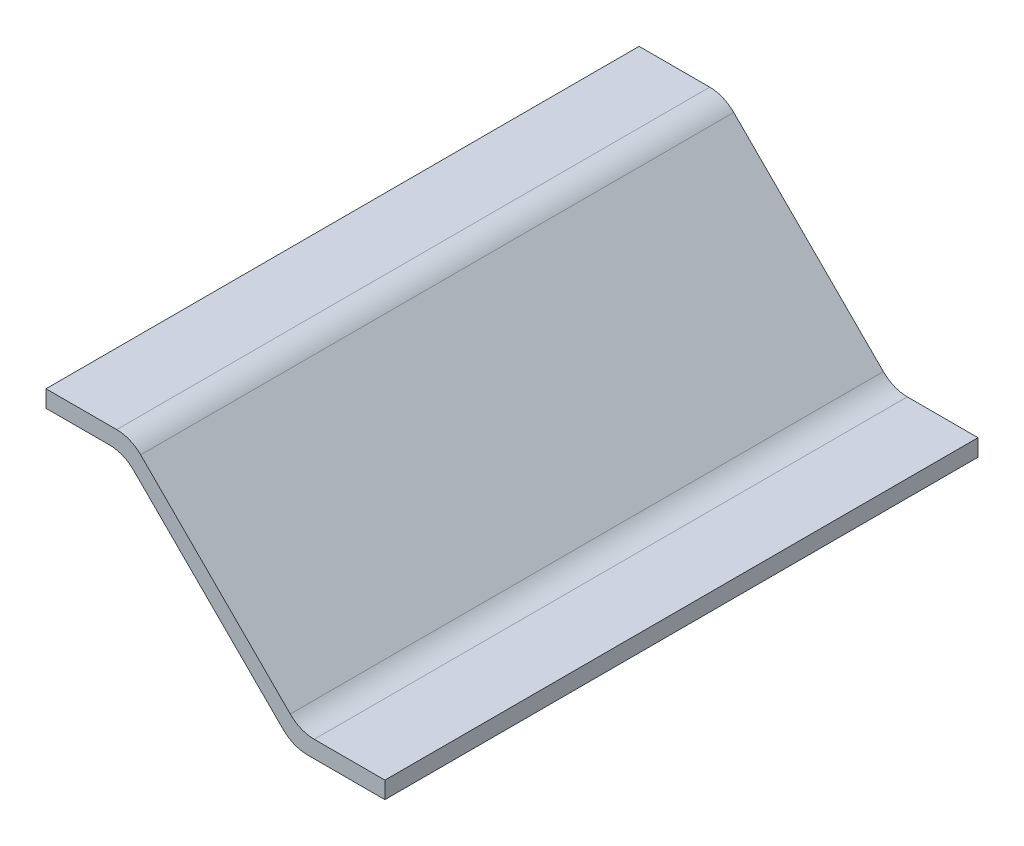
from build123d import *

# Parameters (mm, degrees)
BOSS_EXTRUDE1_DEPTH = 1.75
FILLET4_R           = 0.2


with BuildPart() as part:
    # Sketch4 → Boss-Extrude1 (new body, symmetric)
    with BuildSketch(Plane.XY):
        Polygon((0, 0), (0.5, 0), (1.5, -1), (2, -1), (2, -1.1), (1.458578644, -1.1), (0.458578644, -0.1), (0, -0.1), align=None)
    extrude(amount=BOSS_EXTRUDE1_DEPTH, both=True)

    # Fillet4
    fillet4_edges = [part.edges().sort_by_distance(p)[0] for p in [
        (0.5, 0, 0),
        (1.5, -1, 0),
        (1.458578644, -1.1, 0),
        (0.458578644, -0.1, 0),
    ]]
    fillet(fillet4_edges, radius=FILLET4_R)


solid = part.part
